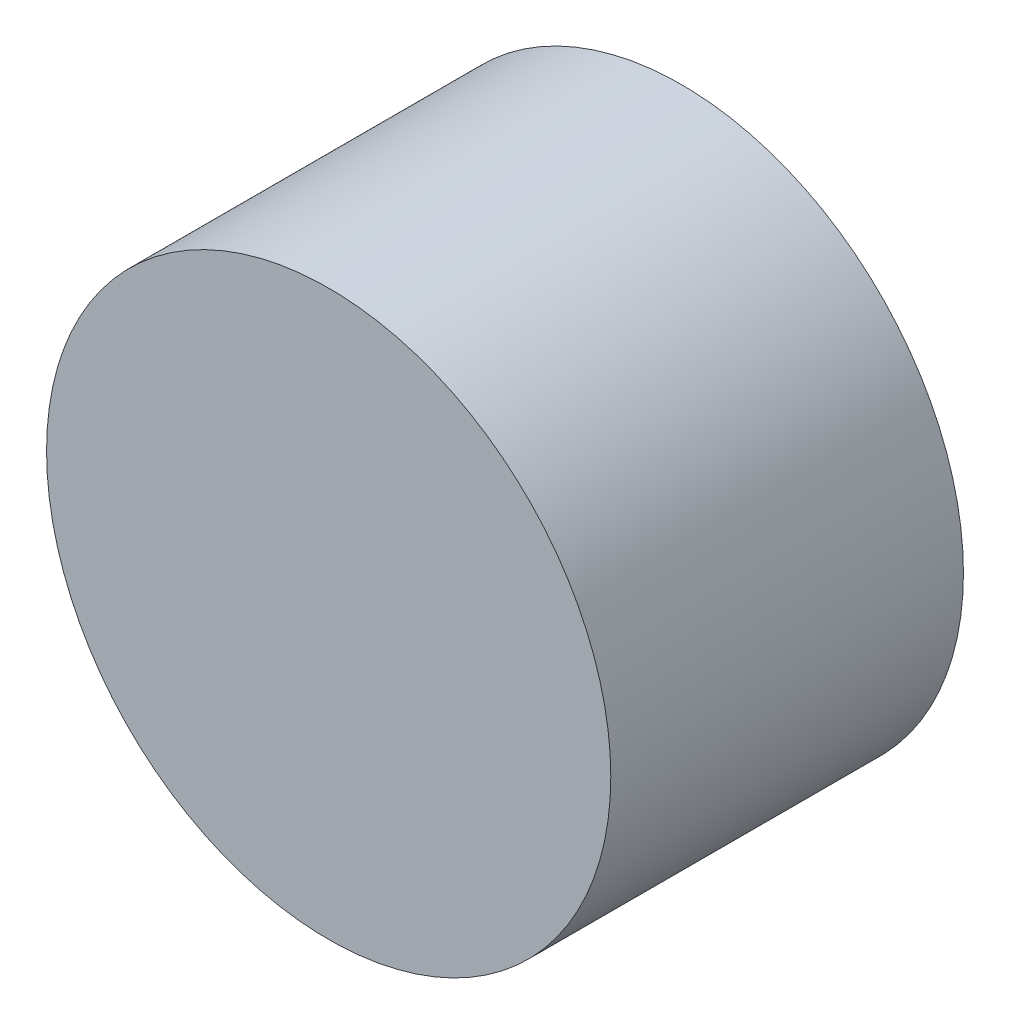
from build123d import *

# Parameters (mm, degrees)
SKETCH1_R           = 25.4
BOSS_EXTRUDE1_DEPTH = 31.75


with BuildPart() as part:
    # Sketch1 → Boss-Extrude1 (new body)
    with BuildSketch(Plane.XY):
        Circle(SKETCH1_R)
    extrude(amount=BOSS_EXTRUDE1_DEPTH)


solid = part.part
